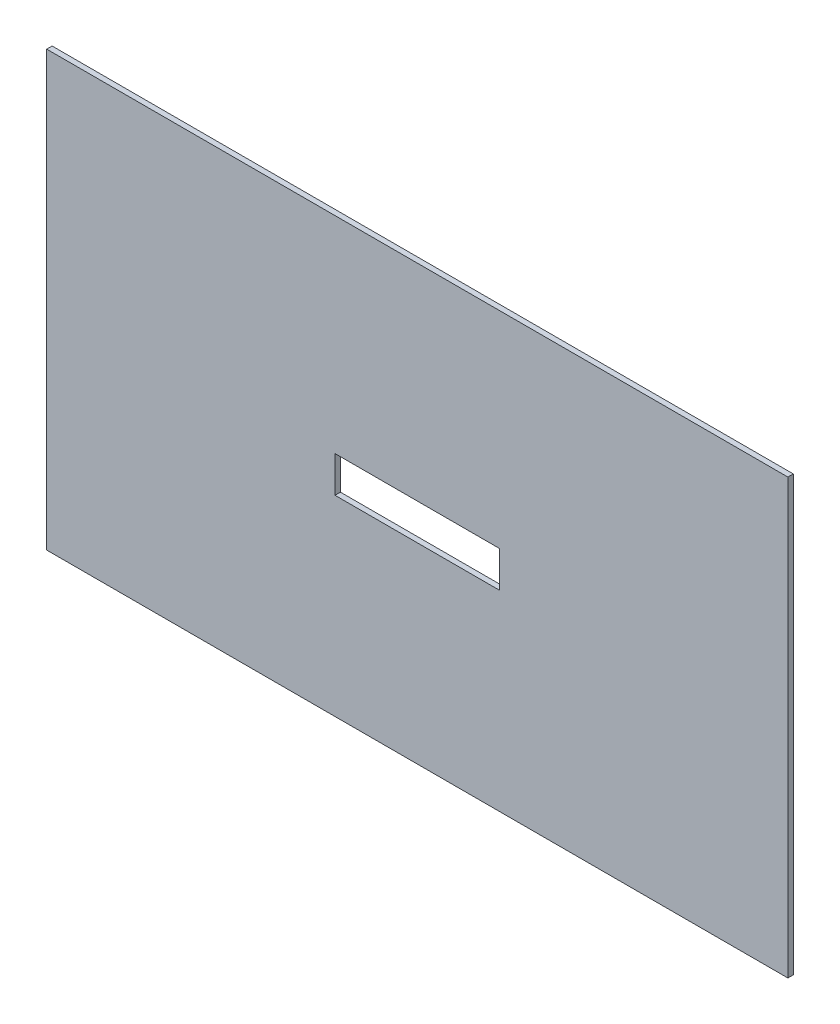
from build123d import *

# Parameters (mm, degrees)
SKETCH1_W           = 410
SKETCH1_H           = 240
BOSS_EXTRUDE1_DEPTH = 1.5
SKETCH2_W           = 91
SKETCH2_H           = 20
CUT_EXTRUDE1_DEPTH  = 4


with BuildPart() as part:
    # Sketch1 → Boss-Extrude1 (new body, symmetric)
    with BuildSketch(Plane.XY):
        Rectangle(SKETCH1_W, SKETCH1_H)
    extrude(amount=BOSS_EXTRUDE1_DEPTH, both=True)

    # Sketch2 → Cut-Extrude1 (cut, through all)
    with BuildSketch(Plane.XY.offset(1.5)):
        with Locations((0, -4)):
            Rectangle(SKETCH2_W, SKETCH2_H)
    extrude(amount=-CUT_EXTRUDE1_DEPTH, mode=Mode.SUBTRACT)


solid = part.part
